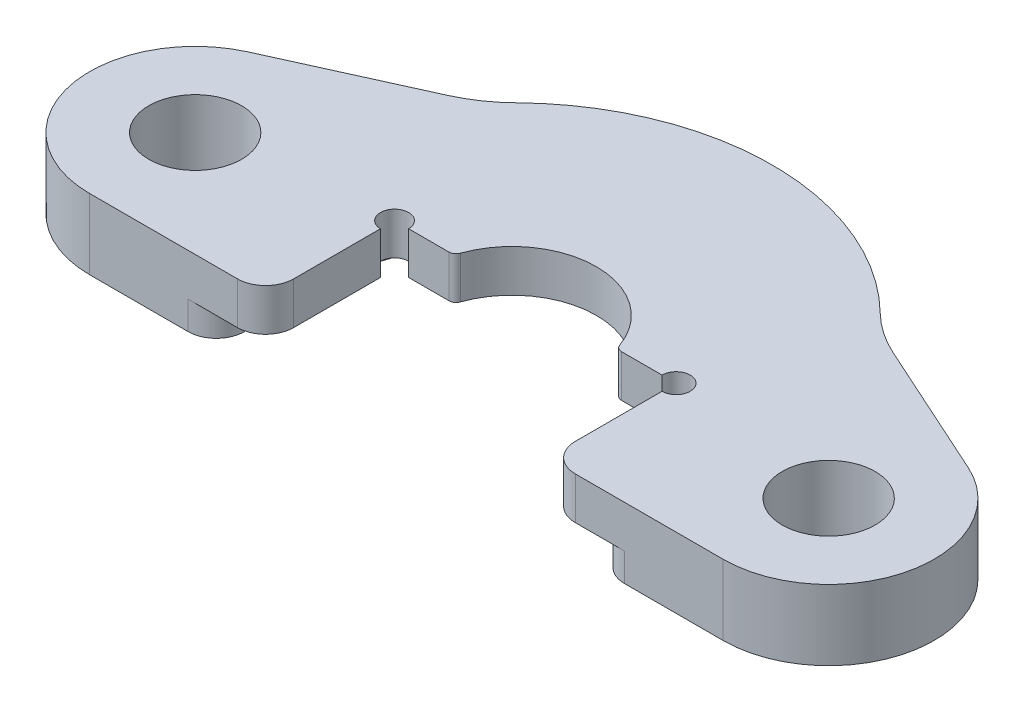
from build123d import *

# Parameters (mm, degrees)
BOSS_EXTRUDE1_DEPTH  = 5
CUT_EXTRUDE1_DEPTH   = 6
FILLET1_R            = 10
M6_CLEARANCE_HOLE1_D = 6.6
FILLET2_R            = 0.5
SKETCH5_R            = 1
CUT_EXTRUDE2_DEPTH   = 6
FILLET3_R            = 2
CUT_EXTRUDE3_DEPTH   = 2
FILLET4_R            = 2


with BuildPart() as part:
    # Sketch1 → Boss-Extrude1 (new body)
    with BuildSketch(Plane(origin=(0, 0, 0), x_dir=(1, 0, 0), z_dir=(0, 1, 0))):
        with BuildLine():
            Line((-25.590540252, 6.833634535), (-14.025260906, 12.064081255))
            ThreePointArc((-14.025260906, 12.064081255), (0, 18.5), (14.025260906, 12.064081255))
            Line((14.025260906, 12.064081255), (25.590540252, 6.833634535))
            ThreePointArc((25.590540252, 6.833634535), (29.83151618, -1.580781609), (22.5, -7.5))
            Line((22.5, -7.5), (-22.5, -7.5))
            ThreePointArc((-22.5, -7.5), (-29.83151618, -1.580781609), (-25.590540252, 6.833634535))
        make_face()
    extrude(amount=BOSS_EXTRUDE1_DEPTH)

    # Sketch2 → Cut-Extrude1 (cut, through all)
    with BuildSketch(Plane(origin=(0, 5, 0), x_dir=(1, 0, 0), z_dir=(0, 1, 0))):
        with BuildLine():
            Line((10, -7.5), (10, 1.661480829))
            Line((10, 1.661480829), (5.765369152, 1.661480829))
            ThreePointArc((5.765369152, 1.661480829), (0, 6), (-5.765369152, 1.661480829))
            Line((-5.765369152, 1.661480829), (-10, 1.661480829))
            Line((-10, 1.661480829), (-10, -7.5))
            Line((-10, -7.5), (10, -7.5))
        make_face()
    extrude(amount=-CUT_EXTRUDE1_DEPTH, mode=Mode.SUBTRACT)

    # Fillet1
    fillet1_edges = [part.edges().sort_by_distance(p)[0] for p in [
        (-14.025260906, 2.5, -12.064081255),
        (14.025260906, 2.5, -12.064081255),
    ]]
    fillet(fillet1_edges, radius=FILLET1_R)

    # M6 Clearance Hole1 (through all)
    with Locations(Plane(origin=(0, 5, 0), x_dir=(1, 0, 0), z_dir=(0, 1, 0))):
        with Locations((-22.5, 0), (22.5, 0)):
            Hole(M6_CLEARANCE_HOLE1_D / 2)

    # Fillet2
    fillet2_edges = [part.edges().sort_by_distance(p)[0] for p in [
        (-5.765369152, 2.5, -1.661480829),
        (5.765369152, 2.5, -1.661480829),
    ]]
    fillet(fillet2_edges, radius=FILLET2_R)

    # Sketch5 → Cut-Extrude2 (cut, through all)
    with BuildSketch(Plane(origin=(0, 5, 0), x_dir=(1, 0, 0), z_dir=(0, 1, 0))):
        with Locations((-10, 1.661480829)):
            Circle(SKETCH5_R)
        with Locations((10, 1.661480829)):
            Circle(SKETCH5_R)
    extrude(amount=-CUT_EXTRUDE2_DEPTH, mode=Mode.SUBTRACT)

    # Fillet3
    fillet3_edges = [part.edges().sort_by_distance(p)[0] for p in [
        (10, 2.5, 7.5),
        (-10, 2.5, 7.5),
    ]]
    fillet(fillet3_edges, radius=FILLET3_R)

    # Sketch6 → Cut-Extrude3 (cut)
    with BuildSketch(Plane.XZ):
        with BuildLine():
            Line((-13.5, 0), (-13.5, 12))
            ThreePointArc((-13.5, 12), (0, 25.5), (13.5, 12))
            Line((13.5, 12), (13.5, 0))
            ThreePointArc((13.5, 0), (0, -13.5), (-13.5, 0))
        make_face()
    extrude(amount=-CUT_EXTRUDE3_DEPTH, mode=Mode.SUBTRACT)

    # Fillet4
    fillet4_edges = [part.edges().sort_by_distance(p)[0] for p in [
        (-13.5, 1, 7.5),
        (13.5, 1, 7.5),
    ]]
    fillet(fillet4_edges, radius=FILLET4_R)


solid = part.part
